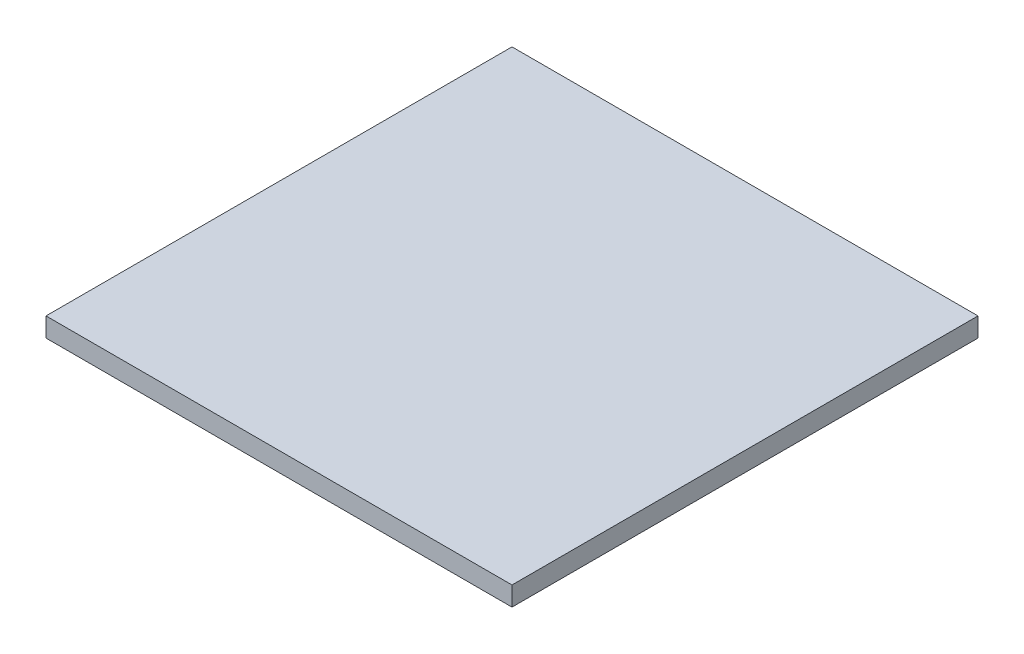
from build123d import *

# Parameters (mm, degrees)
SKETCH1_W           = 77
SKETCH1_H           = 77
BOSS_EXTRUDE1_DEPTH = 3.175


with BuildPart() as part:
    # Sketch1 → Boss-Extrude1 (new body)
    with BuildSketch(Plane(origin=(0, 0, 0), x_dir=(1, 0, 0), z_dir=(0, 1, 0))):
        Rectangle(SKETCH1_W, SKETCH1_H)
    extrude(amount=BOSS_EXTRUDE1_DEPTH)


solid = part.part
